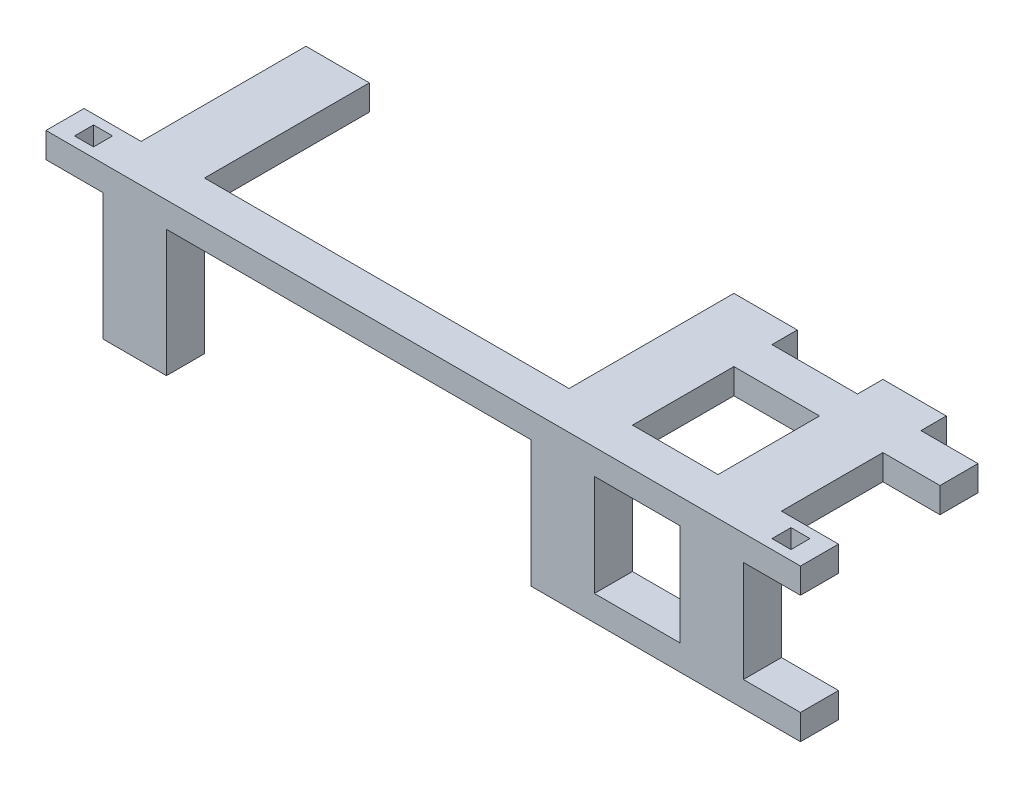
from build123d import *

# Parameters (mm, degrees)
SKETCH1_W           = 119
SKETCH1_H           = 6
BOSS_EXTRUDE1_DEPTH = 4
CUT_EXTRUDE1_REACH  = 6
SKETCH2_W           = 3
SKETCH2_H           = 3
SKETCH3_W           = 10
SKETCH3_H           = 4
BOSS_EXTRUDE2_DEPTH = 26
SKETCH4_W           = 10
SKETCH4_H           = 6
BOSS_EXTRUDE3_DEPTH = 20
SKETCH5_W           = 6
SKETCH5_H           = 4
BOSS_EXTRUDE4_DEPTH = 42.5


with BuildPart() as part:
    # Sketch1 → Boss-Extrude1 (new body)
    with BuildSketch(Plane(origin=(0, 0, 0), x_dir=(1, 0, 0), z_dir=(0, 1, 0))):
        with Locations((59.5, 3)):
            Rectangle(SKETCH1_W, SKETCH1_H)
    extrude(amount=BOSS_EXTRUDE1_DEPTH)

    # Sketch2 → Cut-Extrude1 (cut, up to next)
    with BuildSketch(Plane(origin=(0, 4, 0), x_dir=(1, 0, 0), z_dir=(0, 1, 0)), mode=Mode.PRIVATE) as cut_extrude1_sk1:
        with Locations((114.5, 3)):
            Rectangle(SKETCH2_W, SKETCH2_H)
    cut_extrude1_tool1 = extrude(cut_extrude1_sk1.sketch, amount=-CUT_EXTRUDE1_REACH, mode=Mode.PRIVATE) & part.part
    add(cut_extrude1_tool1.solids().sort_by_distance((114.5, 4, -3))[0], mode=Mode.SUBTRACT)
    # Sketch2 → Cut-Extrude1 (cut, up to next)
    with BuildSketch(Plane(origin=(0, 4, 0), x_dir=(1, 0, 0), z_dir=(0, 1, 0)), mode=Mode.PRIVATE) as cut_extrude1_sk2:
        with Locations((4.5, 3)):
            Rectangle(SKETCH2_W, SKETCH2_H)
    cut_extrude1_tool2 = extrude(cut_extrude1_sk2.sketch, amount=-CUT_EXTRUDE1_REACH, mode=Mode.PRIVATE) & part.part
    add(cut_extrude1_tool2.solids().sort_by_distance((4.5, 4, -3))[0], mode=Mode.SUBTRACT)

    # Sketch3 → Boss-Extrude2 (add)
    with BuildSketch(Plane(origin=(0, 0, -6), x_dir=(-1, 0, 0), z_dir=(0, 0, -1))):
        with Locations((-105, 2)):
            Rectangle(SKETCH3_W, SKETCH3_H)
        with Locations((-81.5, 2)):
            Rectangle(SKETCH3_W, SKETCH3_H)
        with Locations((-14, 2)):
            Rectangle(SKETCH3_W, SKETCH3_H)
    extrude(amount=BOSS_EXTRUDE2_DEPTH)

    # Sketch4 → Boss-Extrude3 (add)
    with BuildSketch(Plane.XZ):
        with Locations((105, -3)):
            Rectangle(SKETCH4_W, SKETCH4_H)
        with Locations((81.5, -3)):
            Rectangle(SKETCH4_W, SKETCH4_H)
        with Locations((14, -3)):
            Rectangle(SKETCH4_W, SKETCH4_H)
    extrude(amount=BOSS_EXTRUDE3_DEPTH)

    # Sketch5 → Boss-Extrude4 (add)
    with BuildSketch(Plane.ZY.offset(-76.5)):
        with Locations((-25, 2)):
            Rectangle(SKETCH5_W, SKETCH5_H)
        with Locations((-3, -18)):
            Rectangle(SKETCH5_W, SKETCH5_H)
    extrude(amount=-BOSS_EXTRUDE4_DEPTH)


solid = part.part
